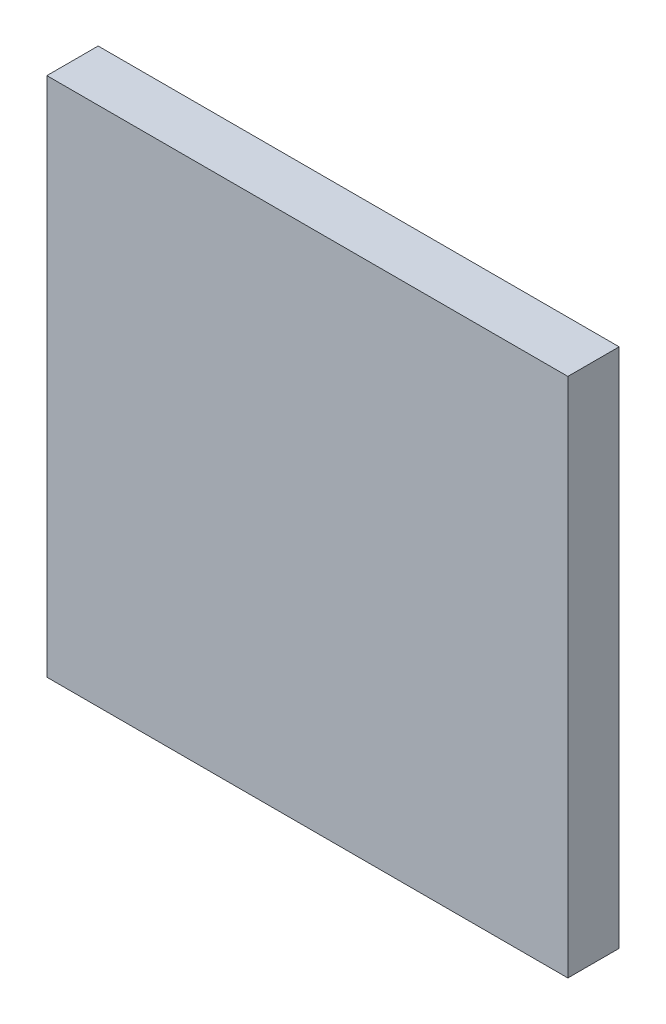
from build123d import *

# Parameters (mm, degrees)
SKETCH1_W           = 25.4
SKETCH1_H           = 25.4
BOSS_EXTRUDE1_DEPTH = 2.5


with BuildPart() as part:
    # Sketch1 → Boss-Extrude1 (new body)
    with BuildSketch(Plane.XY):
        with Locations((12.7, 12.7)):
            Rectangle(SKETCH1_W, SKETCH1_H)
    extrude(amount=BOSS_EXTRUDE1_DEPTH)


solid = part.part
